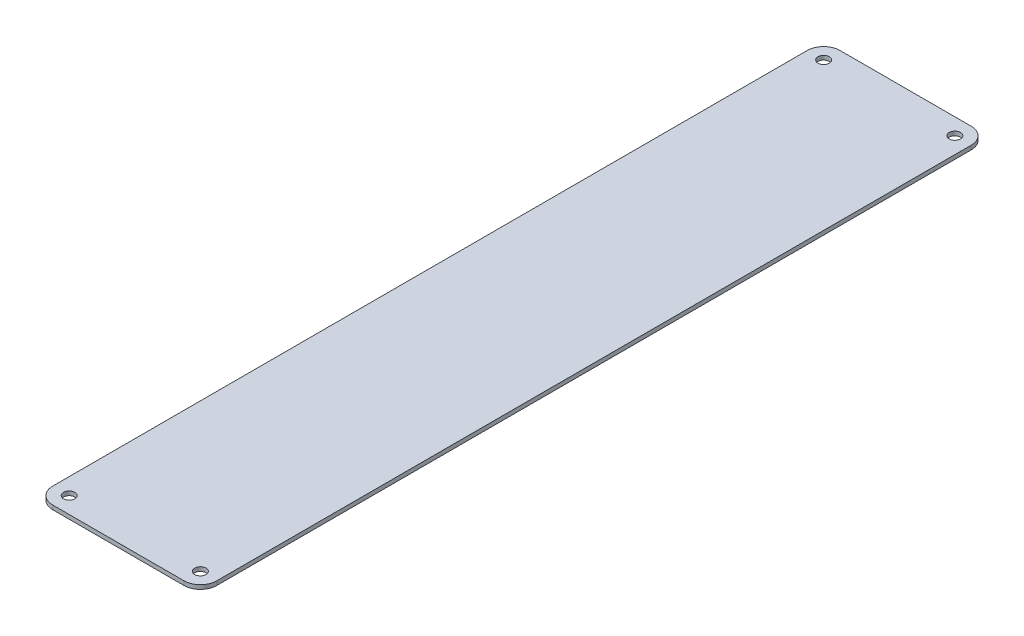
from build123d import *

# Parameters (mm, degrees)
SKETCH1_R           = 2.1828125
BOSS_EXTRUDE1_DEPTH = 0.79375


with BuildPart() as part:
    # Sketch1 → Boss-Extrude1 (new body, symmetric)
    with BuildSketch(Plane(origin=(0, 0, 0), x_dir=(1, 0, 0), z_dir=(0, 1, 0))):
        with BuildLine():
            Line((6.35, 0), (57.15, 0))
            ThreePointArc((57.15, 0), (61.640128061, 1.859871939), (63.5, 6.35))
            Line((63.5, 6.35), (63.5, 298.45))
            ThreePointArc((63.5, 298.45), (61.640128061, 302.940128061), (57.15, 304.8))
            Line((57.15, 304.8), (6.35, 304.8))
            ThreePointArc((6.35, 304.8), (1.859871939, 302.940128061), (0, 298.45))
            Line((0, 298.45), (0, 6.35))
            ThreePointArc((0, 6.35), (1.859871939, 1.859871939), (6.35, 0))
        make_face()
        with Locations((57.15, 298.45)):
            Circle(SKETCH1_R, mode=Mode.SUBTRACT)
        with Locations((6.35, 298.45)):
            Circle(SKETCH1_R, mode=Mode.SUBTRACT)
        with Locations((6.35, 6.35)):
            Circle(SKETCH1_R, mode=Mode.SUBTRACT)
        with Locations((57.15, 6.35)):
            Circle(SKETCH1_R, mode=Mode.SUBTRACT)
    extrude(amount=BOSS_EXTRUDE1_DEPTH, both=True)


solid = part.part
